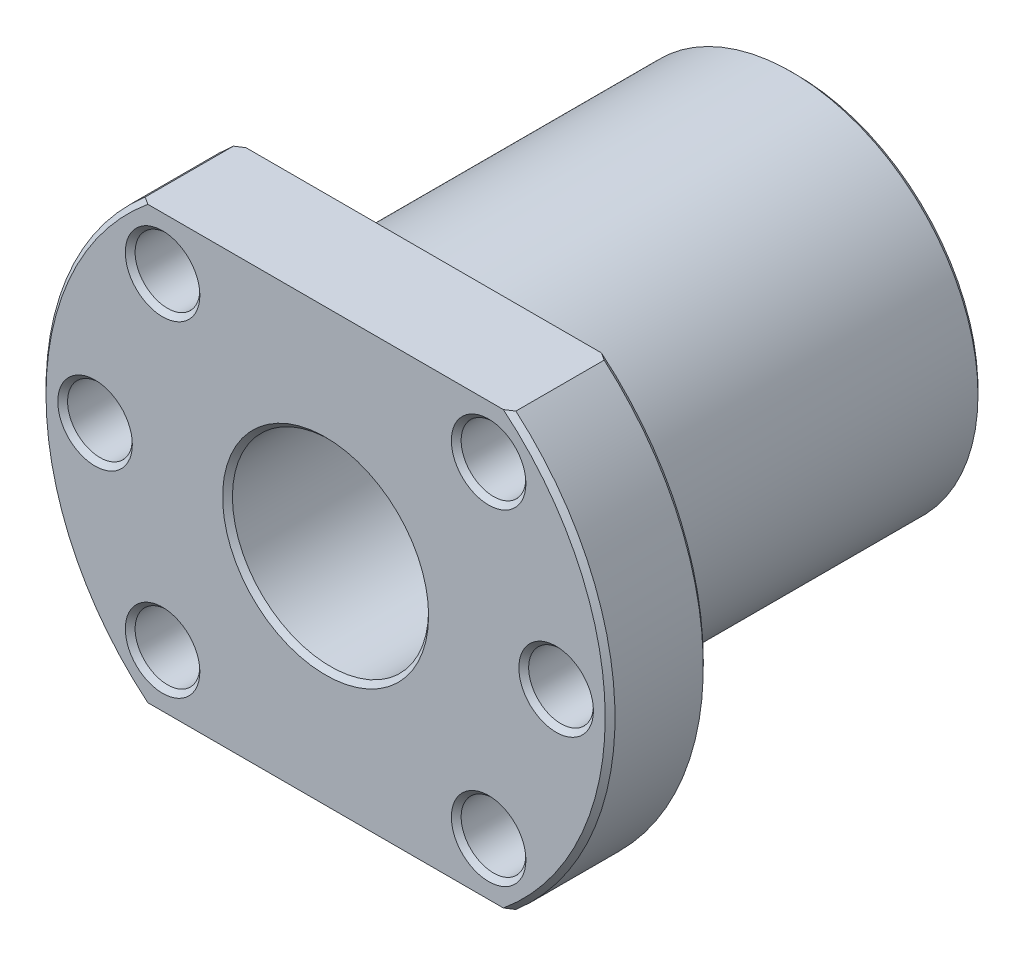
from build123d import *

# Parameters (mm, degrees)
SZKIC1_R                    = 10
SZKIC1_R_2                  = 3.3
DODANIE_WYCI_GNI_CIE1_DEPTH = 10
SZKIC2_R                    = 19
SZKIC2_R_2                  = 10
DODANIE_WYCI_GNI_CIE2_DEPTH = 38
SFAZOWANIE1_SIZE            = 0.5
SFAZOWANIE2_SIZE            = 0.5


with BuildPart() as part:
    # Szkic1 → Dodanie-wyciągnięcie1 (new body)
    with BuildSketch(Plane.XY):
        with BuildLine():
            Line((0, -22), (-18.894443628, -22))
            ThreePointArc((-18.894443628, -22), (-29, 0), (-18.894443628, 22))
            Line((-18.894443628, 22), (0, 22))
            Line((0, 22), (18.894443628, 22))
            ThreePointArc((18.894443628, 22), (29, 0), (18.894443628, -22))
            Line((18.894443628, -22), (0, -22))
        make_face()
        Circle(SZKIC1_R, mode=Mode.SUBTRACT)
        with Locations((-16.617009358, 16.617009358)):
            Circle(SZKIC1_R_2, mode=Mode.SUBTRACT)
        with Locations((-23.5, 0)):
            Circle(SZKIC1_R_2, mode=Mode.SUBTRACT)
        with Locations((-16.617009358, -16.617009358)):
            Circle(SZKIC1_R_2, mode=Mode.SUBTRACT)
        with Locations((16.617009358, -16.617009358)):
            Circle(SZKIC1_R_2, mode=Mode.SUBTRACT)
        with Locations((23.5, 0)):
            Circle(SZKIC1_R_2, mode=Mode.SUBTRACT)
        with Locations((16.617009358, 16.617009358)):
            Circle(SZKIC1_R_2, mode=Mode.SUBTRACT)
    extrude(amount=DODANIE_WYCI_GNI_CIE1_DEPTH)

    # Szkic2 → Dodanie-wyciągnięcie2 (add)
    with BuildSketch(Plane(origin=(0, 0, 0), x_dir=(-1, 0, 0), z_dir=(0, 0, -1))):
        Circle(SZKIC2_R)
        Circle(SZKIC2_R_2, mode=Mode.SUBTRACT)
    extrude(amount=DODANIE_WYCI_GNI_CIE2_DEPTH)

    # Sfazowanie1
    sfazowanie1_edges = [part.edges().sort_by_distance(p)[0] for p in [
        (-19.917009358, 16.617009358, 0),
        (-19.917009358, 16.617009358, 10),
        (-26.8, 0, 0),
        (-26.8, 0, 10),
        (-19.917009358, -16.617009358, 0),
        (-19.917009358, -16.617009358, 10),
        (13.317009358, -16.617009358, 0),
        (13.317009358, -16.617009358, 10),
        (20.2, 0, 0),
        (20.2, 0, 10),
        (13.317009358, 16.617009358, 0),
        (13.317009358, 16.617009358, 10),
    ]]
    chamfer(sfazowanie1_edges, length=SFAZOWANIE1_SIZE)

    # Sfazowanie2
    sfazowanie2_edges = [part.edges().sort_by_distance(p)[0] for p in [
        (29, 0, 10),
        (-10, 0, 10),
        (-29, 0, 10),
        (19, 0, -38),
        (10, 0, -38),
        (29, 0, 0),
        (-29, 0, 0),
    ]]
    chamfer(sfazowanie2_edges, length=SFAZOWANIE2_SIZE)


solid = part.part
